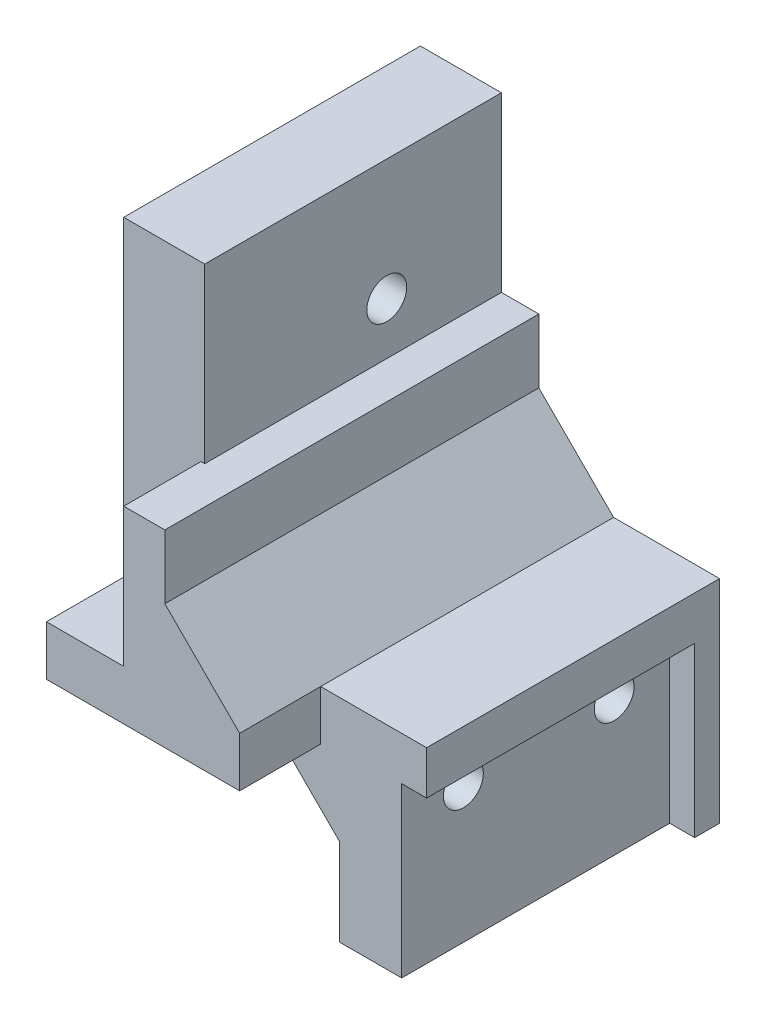
from build123d import *

# Parameters (mm, degrees)
SALIENTE_EXTRUIR1_DEPTH           = 2
SALIENTE_EXTRUIR4_DEPTH           = 28
CROQUIS6_W                        = 6.2
CROQUIS6_H                        = 25
CORTAR_EXTRUIR2_DEPTH             = 6.2
CORTAR_EXTRUIR3_REACH             = 24
CROQUIS7_R                        = 1.6
CORTAR_EXTRUIR4_REACH             = 25.8
CROQUIS8_R                        = 1.6
CORTAR_EXTRUIR5_DEPTH             = 16.8
CORTAR_EXTRUIR6_DEPTH             = 2.5
CORTAR_EXTRUIR6_DIRECTION_2_REACH = 19
CROQUIS11_W                       = 0.3
CROQUIS11_H                       = 13.87
CORTAR_EXTRUIR7_DEPTH             = 6.2
CORTAR_EXTRUIR8_REACH             = 8.5
CROQUIS12_R                       = 1.6
CORTAR_EXTRUIR9_DEPTH             = 3
CORTAR_EXTRUIR10_DEPTH            = 6.5


with BuildPart() as part:
    # Croquis1 → Saliente-Extruir1 (new body)
    with BuildSketch(Plane.XY):
        Polygon((0, 0), (0, -4), (11, -4), (17, -10), (17, -17), (24, -17), (24, 0), (15.5, 0), (9.5, 6), (9.5, 11.13), (6.5, 11.13), (6.5, 25), (0, 25), align=None)
    extrude(amount=SALIENTE_EXTRUIR1_DEPTH)

    # Croquis5 → Saliente-Extruir4 (add)
    with BuildSketch(Plane.XY.offset(2)):
        Polygon((22, -17), (22, -3.5), (24, -3.5), (24, 0), (15.5, 0), (9.5, 6), (9.5, 11.13), (6.5, 11.13), (6.5, 25), (0, 25), (0, -4), (11, -4), (17, -10), (17, -17), align=None)
    extrude(amount=SALIENTE_EXTRUIR4_DEPTH)

    # Croquis6 → Cortar-Extruir2 (cut)
    with BuildSketch(Plane.XY.offset(30)):
        with Locations((3.1, 12.5)):
            Rectangle(CROQUIS6_W, CROQUIS6_H)
    extrude(amount=-CORTAR_EXTRUIR2_DEPTH, mode=Mode.SUBTRACT)

    # Croquis7 → Cortar-Extruir3 (cut, up to next)
    with BuildSketch(Plane(origin=(22, 0, 0), x_dir=(0, 0, -1), z_dir=(1, 0, 0)), mode=Mode.PRIVATE) as cortar_extruir3_sk1:
        with Locations((-18.55, -6.05)):
            Circle(CROQUIS7_R)
    cortar_extruir3_tool1 = extrude(cortar_extruir3_sk1.sketch, amount=-CORTAR_EXTRUIR3_REACH, mode=Mode.PRIVATE) & part.part
    add(cortar_extruir3_tool1.solids().sort_by_distance((22, -6.05, 18.55))[0], mode=Mode.SUBTRACT)
    # Croquis7 → Cortar-Extruir3 (cut, up to next)
    with BuildSketch(Plane(origin=(22, 0, 0), x_dir=(0, 0, -1), z_dir=(1, 0, 0)), mode=Mode.PRIVATE) as cortar_extruir3_sk2:
        with Locations((-6.45, -6.05)):
            Circle(CROQUIS7_R)
    cortar_extruir3_tool2 = extrude(cortar_extruir3_sk2.sketch, amount=-CORTAR_EXTRUIR3_REACH, mode=Mode.PRIVATE) & part.part
    add(cortar_extruir3_tool2.solids().sort_by_distance((22, -6.05, 6.45))[0], mode=Mode.SUBTRACT)

    # Croquis8 → Cortar-Extruir4 (cut, up to next)
    with BuildSketch(Plane.XY.offset(23.8), mode=Mode.PRIVATE) as cortar_extruir4_sk1:
        with Locations((3.1, 4)):
            Circle(CROQUIS8_R)
    cortar_extruir4_tool1 = extrude(cortar_extruir4_sk1.sketch, amount=-CORTAR_EXTRUIR4_REACH, mode=Mode.PRIVATE) & part.part
    add(cortar_extruir4_tool1.solids().sort_by_distance((3.1, 4, 23.8))[0], mode=Mode.SUBTRACT)

    # Croquis9 → Cortar-Extruir5 (cut)
    with BuildSketch(Plane(origin=(0, 0, 0), x_dir=(-1, 0, 0), z_dir=(0, 0, -1))):
        Polygon((-5.95, 2.354551733), (-3.1, 0.709103466), (-0.25, 2.354551733), (-0.25, 5.645448267), (-3.1, 7.290896534), (-5.95, 5.645448267), align=None)
    extrude(amount=-CORTAR_EXTRUIR5_DEPTH, mode=Mode.SUBTRACT)

    # Croquis10 → Cortar-Extruir6 (cut)
    with BuildSketch(Plane.ZY.offset(-17)):
        Polygon((3.159103466, -6.05), (4.804551733, -8.9), (8.095448267, -8.9), (9.740896534, -6.05), (8.095448267, -3.2), (4.804551733, -3.2), align=None)
        Polygon((15.259103466, -6.05), (16.904551733, -8.9), (20.195448267, -8.9), (21.840896534, -6.05), (20.195448267, -3.2), (16.904551733, -3.2), align=None)
    extrude(amount=-CORTAR_EXTRUIR6_DEPTH, mode=Mode.SUBTRACT)

    # Croquis10 → Cortar-Extruir6 direction 2 (cut, up to next)
    with BuildSketch(Plane.ZY.offset(-17), mode=Mode.PRIVATE) as cortar_extruir6_direction_2_sk1:
        Polygon((3.159103466, -6.05), (4.804551733, -8.9), (8.095448267, -8.9), (9.740896534, -6.05), (8.095448267, -3.2), (4.804551733, -3.2), align=None)
    cortar_extruir6_direction_2_tool1 = extrude(cortar_extruir6_direction_2_sk1.sketch, amount=CORTAR_EXTRUIR6_DIRECTION_2_REACH, mode=Mode.PRIVATE) & part.part
    add(cortar_extruir6_direction_2_tool1.solids().sort_by_distance((17, -6.05, 6.45))[0], mode=Mode.SUBTRACT)
    # Croquis10 → Cortar-Extruir6 direction 2 (cut, up to next)
    with BuildSketch(Plane.ZY.offset(-17), mode=Mode.PRIVATE) as cortar_extruir6_direction_2_sk2:
        Polygon((15.259103466, -6.05), (16.904551733, -8.9), (20.195448267, -8.9), (21.840896534, -6.05), (20.195448267, -3.2), (16.904551733, -3.2), align=None)
    cortar_extruir6_direction_2_tool2 = extrude(cortar_extruir6_direction_2_sk2.sketch, amount=CORTAR_EXTRUIR6_DIRECTION_2_REACH, mode=Mode.PRIVATE) & part.part
    add(cortar_extruir6_direction_2_tool2.solids().sort_by_distance((17, -6.05, 18.55))[0], mode=Mode.SUBTRACT)

    # Croquis11 → Cortar-Extruir7 (cut)
    with BuildSketch(Plane.XY.offset(30)):
        with Locations((6.35, 18.065)):
            Rectangle(CROQUIS11_W, CROQUIS11_H)
    extrude(amount=-CORTAR_EXTRUIR7_DEPTH, mode=Mode.SUBTRACT)

    # Croquis12 → Cortar-Extruir8 (cut, up to next)
    with BuildSketch(Plane(origin=(6.5, 0, 0), x_dir=(0, 0, -1), z_dir=(1, 0, 0)), mode=Mode.PRIVATE) as cortar_extruir8_sk1:
        with Locations((-9.2, 15.3)):
            Circle(CROQUIS12_R)
    cortar_extruir8_tool1 = extrude(cortar_extruir8_sk1.sketch, amount=-CORTAR_EXTRUIR8_REACH, mode=Mode.PRIVATE) & part.part
    add(cortar_extruir8_tool1.solids().sort_by_distance((6.5, 15.3, 9.2))[0], mode=Mode.SUBTRACT)

    # Croquis13 → Cortar-Extruir9 (cut)
    with BuildSketch(Plane.ZY):
        Polygon((9.2, 18.590896534), (6.35, 16.945448267), (6.35, 13.654551733), (9.2, 12.009103466), (12.05, 13.654551733), (12.05, 16.945448267), align=None)
    extrude(amount=-CORTAR_EXTRUIR9_DEPTH, mode=Mode.SUBTRACT)

    # Croquis14 → Cortar-Extruir10 (cut)
    with BuildSketch(Plane.XY.offset(30)):
        Polygon((15.5, 0), (15.5, -4), (11, -4), (17, -10), (17, -17), (22, -17), (22, -3.5), (24, -3.5), (24, 0), align=None)
    extrude(amount=-CORTAR_EXTRUIR10_DEPTH, mode=Mode.SUBTRACT)


solid = part.part
